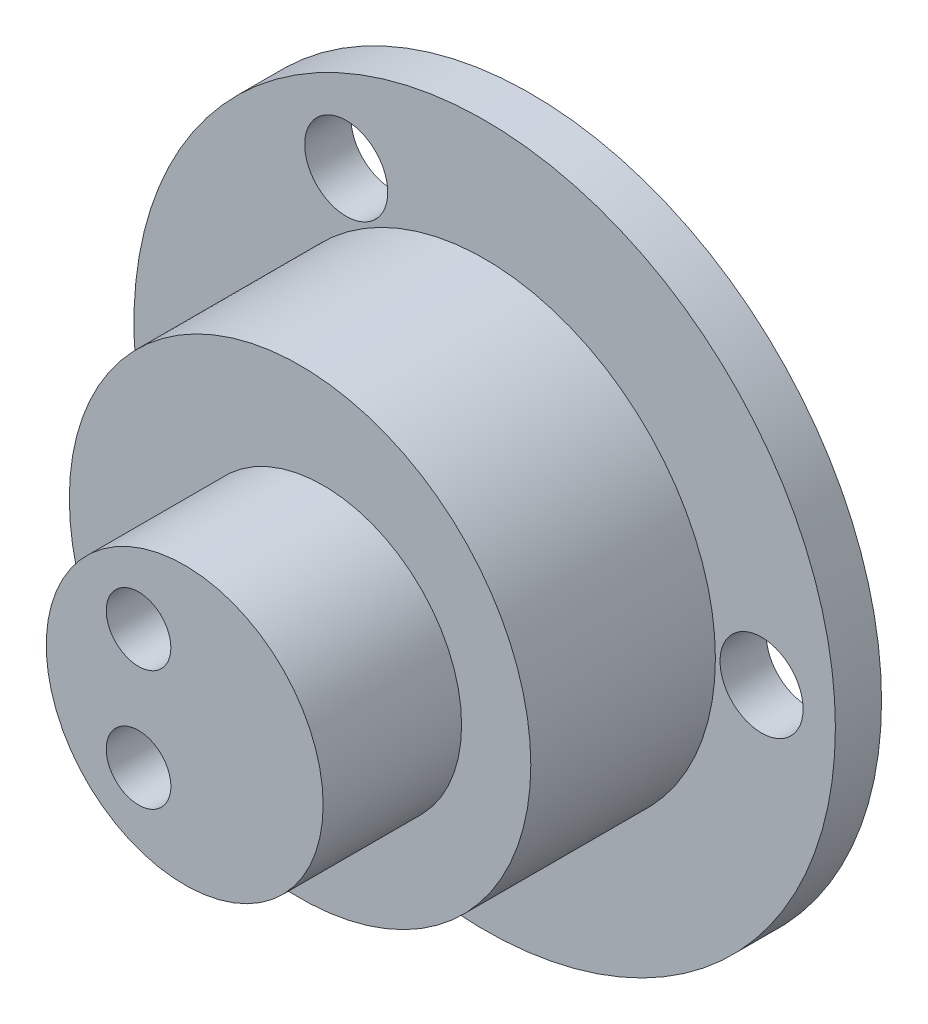
from build123d import *

# Parameters (mm, degrees)
SKETCH_1_R          = 7.5
SKETCH_1_R_2        = 0.9
SKETCH_1_R_3        = 4.45
EXTRUDE_1_DEPTH     = 1
SKETCH_2_R          = 5
EXTRUDE_2_DEPTH     = 4
SKETCH_3_R          = 4.45
CUT_EXTRUDE_1_DEPTH = 1
SKETCH_5_R          = 3
EXTRUDE_4_DEPTH     = 3
SKETCH_6_R          = 9
SKETCH_6_R_2        = 0.9
SKETCH_6_R_3        = 4.45
EXTRUDE_7_DEPTH     = 1
SKETCH_7_R          = 0.7
CUT_EXTRUDE_2_DEPTH = 10
SKETCH_8_R          = 9
SKETCH_8_R_2        = 7.6
CUT_EXTRUDE_3_DEPTH = 10


with BuildPart() as part:
    # 草图1 → 凸台-拉伸1 (new body)
    with BuildSketch(Plane.XY):
        Circle(SKETCH_1_R)
        with Locations((6, 0)):
            Circle(SKETCH_1_R_2, mode=Mode.SUBTRACT)
        with Locations((-3, -5.196152423)):
            Circle(SKETCH_1_R_2, mode=Mode.SUBTRACT)
        with Locations((-3, 5.196152423)):
            Circle(SKETCH_1_R_2, mode=Mode.SUBTRACT)
        Circle(SKETCH_1_R_3, mode=Mode.SUBTRACT)
    extrude(amount=EXTRUDE_1_DEPTH)

    # 草图2 → 凸台-拉伸2 (add)
    with BuildSketch(Plane.XY.offset(1)):
        Circle(SKETCH_2_R)
    extrude(amount=EXTRUDE_2_DEPTH)

    # 草图3 → 切除-拉伸1 (cut)
    with BuildSketch(Plane(origin=(0, 0, 1), x_dir=(-1, 0, 0), z_dir=(0, 0, -1))):
        Circle(SKETCH_3_R)
    extrude(amount=-CUT_EXTRUDE_1_DEPTH, mode=Mode.SUBTRACT)

    # 草图5 → 凸台-拉伸4 (add)
    with BuildSketch(Plane.XY.offset(5)):
        with Locations((0.5, 0)):
            Circle(SKETCH_5_R)
    extrude(amount=EXTRUDE_4_DEPTH)

    # 草图6 → 凸台-拉伸7 (add)
    with BuildSketch(Plane.XY.offset(1)):
        Circle(SKETCH_6_R)
        with Locations((6, 0)):
            Circle(SKETCH_6_R_2, mode=Mode.SUBTRACT)
        with Locations((-3, 5.196152423)):
            Circle(SKETCH_6_R_2, mode=Mode.SUBTRACT)
        with Locations((-3, -5.196152423)):
            Circle(SKETCH_6_R_2, mode=Mode.SUBTRACT)
        Circle(SKETCH_6_R_3, mode=Mode.SUBTRACT)
    extrude(amount=-EXTRUDE_7_DEPTH)

    # 草图7 → 切除-拉伸2 (cut)
    with BuildSketch(Plane.XY.offset(8)):
        with Locations((-0.5, 1.3)):
            Circle(SKETCH_7_R)
        with Locations((-0.5, -1.3)):
            Circle(SKETCH_7_R)
    extrude(amount=-CUT_EXTRUDE_2_DEPTH, mode=Mode.SUBTRACT)

    # 草图8 → 切除-拉伸3 (cut)
    with BuildSketch(Plane.XY.offset(1)):
        Circle(SKETCH_8_R)
        Circle(SKETCH_8_R_2, mode=Mode.SUBTRACT)
    extrude(amount=-CUT_EXTRUDE_3_DEPTH, mode=Mode.SUBTRACT)


solid = part.part
